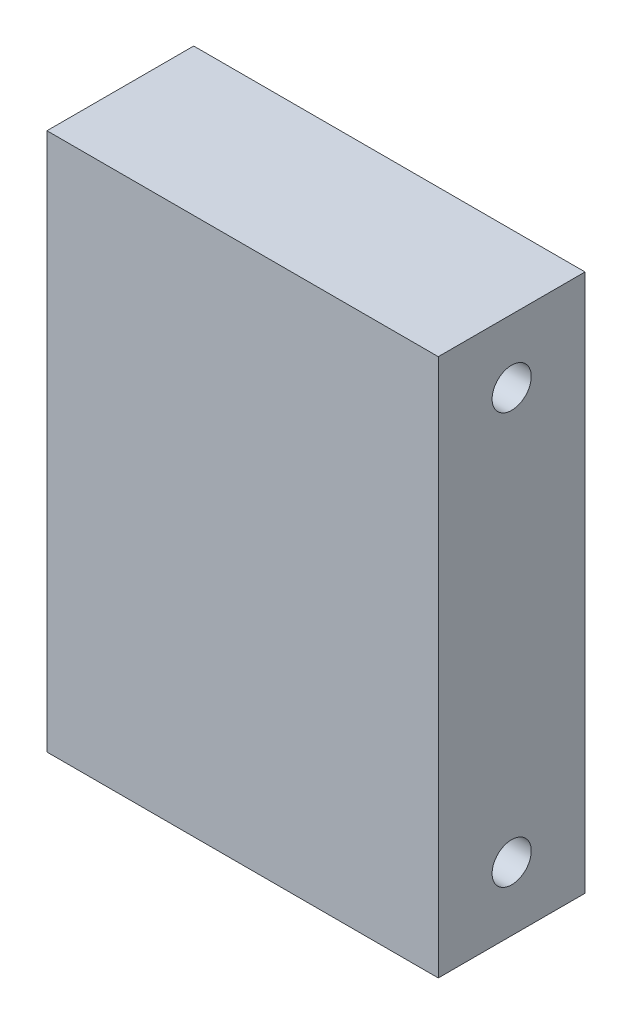
from build123d import *

# Parameters (mm, degrees)
ESQUISSE1_W             = 40
ESQUISSE1_H             = 55
BOSS_EXTRU_1_DEPTH      = 15
ESQUISSE2_R             = 2
ENL_V_MAT_EXTRU_1_DEPTH = 5
ESQUISSE3_R             = 2
ENL_V_MAT_EXTRU_2_DEPTH = 5


with BuildPart() as part:
    # Esquisse1 → Boss.-Extru.1 (new body)
    with BuildSketch(Plane.XY):
        Rectangle(ESQUISSE1_W, ESQUISSE1_H)
    extrude(amount=BOSS_EXTRU_1_DEPTH)

    # Esquisse2 → Enlèv. mat.-Extru.1 (cut)
    with BuildSketch(Plane(origin=(20, 0, 0), x_dir=(0, 0, -1), z_dir=(1, 0, 0))):
        with Locations((-7.5, 21)):
            Circle(ESQUISSE2_R)
        with Locations((-7.5, -21)):
            Circle(ESQUISSE2_R)
    extrude(amount=-ENL_V_MAT_EXTRU_1_DEPTH, mode=Mode.SUBTRACT)

    # Esquisse3 → Enlèv. mat.-Extru.2 (cut)
    with BuildSketch(Plane.ZY.offset(20)):
        with Locations((7.5, 21)):
            Circle(ESQUISSE3_R)
        with Locations((7.5, -21)):
            Circle(ESQUISSE3_R)
    extrude(amount=-ENL_V_MAT_EXTRU_2_DEPTH, mode=Mode.SUBTRACT)


solid = part.part
